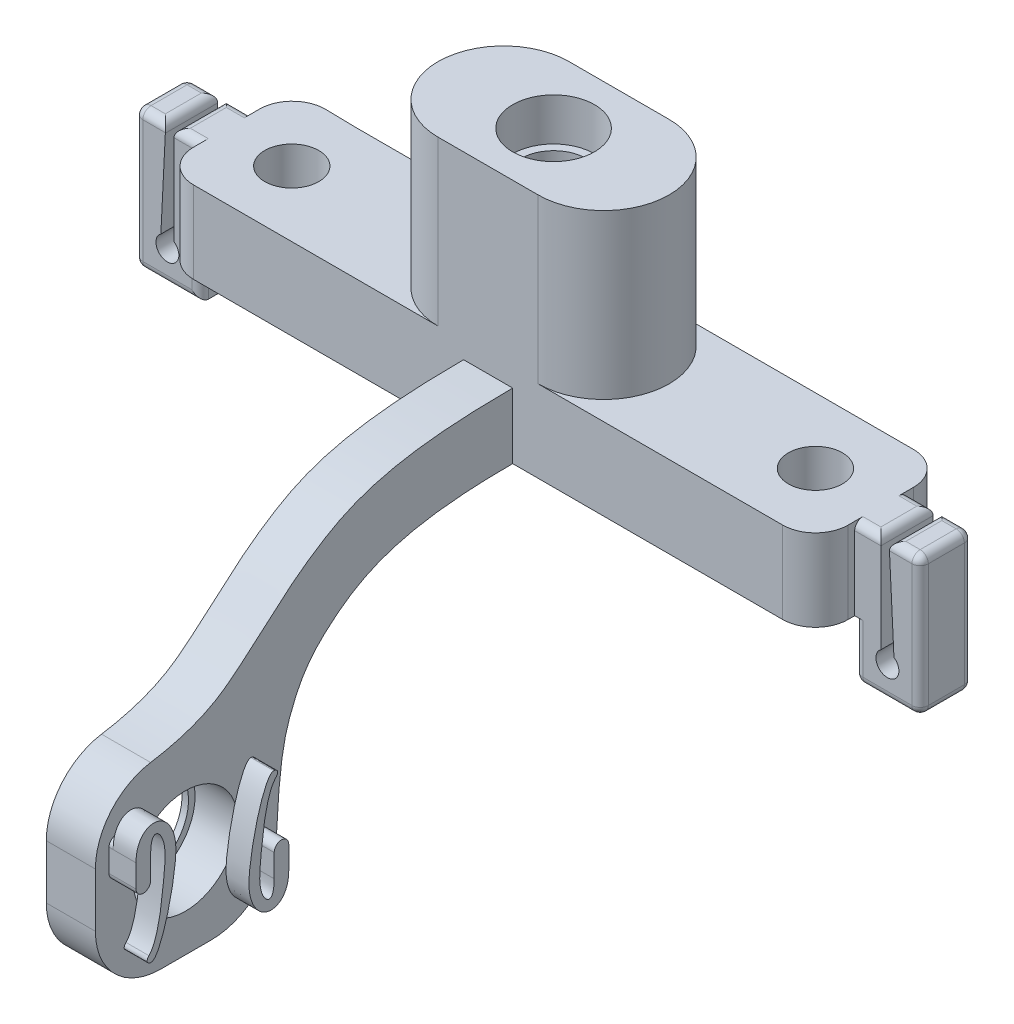
from build123d import *

# Parameters (mm, degrees)
SKETCH1_R                      = 1.65
BOSS_EXTRUDE1_DEPTH            = 5
SKETCH6_R                      = 2.5
CUT_EXTRUDE1_DEPTH             = 2.6
BOSS_EXTRUDE2_DEPTH            = 10
SKETCH8_R                      = 2.5
CUT_EXTRUDE2_DEPTH             = 2.6
SKETCH9_R                      = 2
CUT_EXTRUDE3_DEPTH             = 1.0000001
CUT_EXTRUDE3_DEPTH_BACK        = 16.0000001
BOSS_EXTRUDE3_DEPTH            = 1.6
BOSS_EXTRUDE3_DEPTH_BACK       = 1.6
CUT_EXTRUDE4_REACH             = 6.069
CUT_EXTRUDE4_DIRECTION_2_REACH = 6
FILLET1_R                      = 0.5
FILLET2_R                      = 2
SKETCH14_R                     = 3.19
BOSS_EXTRUDE5_DEPTH            = 1.5
BOSS_EXTRUDE5_DEPTH_BACK       = 1.5
FILLET3_R                      = 4
BOSS_EXTRUDE6_START            = 0.25
BOSS_EXTRUDE6_DEPTH            = 1.4
BOSS_EXTRUDE6_2_DEPTH          = 1.4
BOSS_EXTRUDE7_DEPTH            = 0.25
SKETCH17_R                     = 3.19
SKETCH17_R_2                   = 2.79
BOSS_EXTRUDE8_DEPTH            = 0.4


with BuildPart() as part:
    # Sketch1 → Boss-Extrude1 (new body)
    with BuildSketch(Plane(origin=(0, 0, 0), x_dir=(1, 0, 0), z_dir=(0, 1, 0))):
        with BuildLine():
            Line((16, -4), (20, -4))
            Line((20, -4), (20, 4))
            Line((20, 4), (16, 4))
            add(Edge.make_bspline(
                [(16, 4), (9.039795661, 4), (0.632100921, 4), (-10.303997503, 4), (-16, 4)],
                knots=[0, 0, 0, 0, 0.5, 1, 1, 1, 1], degree=3))
            Line((-16, 4), (-20, 4.068954941))
            Line((-20, 4.068954941), (-20, -4))
            Line((-20, -4), (-16, -4))
            add(Edge.make_bspline(
                [(16, -4), (10.303997503, -4), (-0.632100921, -4), (-9.039795661, -4), (-16, -4)],
                knots=[0, 0, 0, 0, 0.5, 1, 1, 1, 1], degree=3))
        make_face()
        with Locations((-16, 0)):
            Circle(SKETCH1_R, mode=Mode.SUBTRACT)
        with Locations((16, 0)):
            Circle(SKETCH1_R, mode=Mode.SUBTRACT)
    extrude(amount=BOSS_EXTRUDE1_DEPTH)

    # Sketch6 → Cut-Extrude1 (cut)
    with BuildSketch(Plane.XZ):
        Circle(SKETCH6_R)
    extrude(amount=-CUT_EXTRUDE1_DEPTH, mode=Mode.SUBTRACT)

    # Sketch7 → Boss-Extrude2 (add)
    with BuildSketch(Plane(origin=(0, 5, 0), x_dir=(1, 0, 0), z_dir=(0, 1, 0))):
        with BuildLine():
            Line((3.058707684, -4), (-3.058707684, -4))
            ThreePointArc((-3.058707684, -4), (-7.058707684, 0), (-3.058707684, 4))
            Line((-3.058707684, 4), (3.058707684, 4))
            ThreePointArc((3.058707684, 4), (7.058707684, 0), (3.058707684, -4))
        make_face()
    extrude(amount=BOSS_EXTRUDE2_DEPTH)

    # Sketch8 → Cut-Extrude2 (cut)
    with BuildSketch(Plane(origin=(0, 15, 0), x_dir=(1, 0, 0), z_dir=(0, 1, 0))):
        Circle(SKETCH8_R)
    extrude(amount=-CUT_EXTRUDE2_DEPTH, mode=Mode.SUBTRACT)

    # Sketch9 → Cut-Extrude3 (cut, two sides)
    with BuildSketch(Plane(origin=(0, 15, 0), x_dir=(1, 0, 0), z_dir=(0, 1, 0))) as cut_extrude3_sk:
        Circle(SKETCH9_R)
    extrude(amount=CUT_EXTRUDE3_DEPTH, mode=Mode.SUBTRACT)
    extrude(cut_extrude3_sk.sketch, amount=-CUT_EXTRUDE3_DEPTH_BACK, mode=Mode.SUBTRACT)

    # Sketch10 → Boss-Extrude3 (add, two sides)
    with BuildSketch(Plane.XY) as boss_extrude3_sk:
        Polygon((20, 5), (24, 5), (24, -3.5), (20, -3.5), (20, 0), align=None)
        Polygon((-20, -3.5), (-20, 0), (-20, 5), (-24, 5), (-24, -3.5), align=None)
    extrude(amount=BOSS_EXTRUDE3_DEPTH)
    extrude(boss_extrude3_sk.sketch, amount=-BOSS_EXTRUDE3_DEPTH_BACK)

    # Cut-Extrude4: up to this face of the body (flat: up to its plane)
    cut_extrude4_end = Plane(part.part.faces().sort_by_distance((-22, 0.75, -1.6))[0])
    # Sketch11 → Cut-Extrude4 (cut, up to the picked face)
    with BuildSketch(Plane.XY, mode=Mode.PRIVATE) as cut_extrude4_sk1:
        with BuildLine():
            Line((21.6, 5), (21.6, -1))
            ThreePointArc((21.6, -1), (22, -2.274456265), (22.4, -1))
            Line((22.4, -1), (22.1, 5))
            Line((22.1, 5), (21.6, 5))
        make_face()
    cut_extrude4_tool1 = split(extrude(cut_extrude4_sk1.sketch, amount=-CUT_EXTRUDE4_REACH, mode=Mode.PRIVATE), bisect_by=cut_extrude4_end, keep=Keep.BOTH, mode=Mode.PRIVATE)
    add(cut_extrude4_tool1.solids().sort_by_distance((21.949731, 0.845469, 0))[0], mode=Mode.SUBTRACT)
    # Sketch11 → Cut-Extrude4 (cut, up to the picked face)
    with BuildSketch(Plane.XY, mode=Mode.PRIVATE) as cut_extrude4_sk2:
        with BuildLine():
            Line((-22.1, 5), (-22.4, -1))
            ThreePointArc((-22.4, -1), (-22, -2.274456265), (-21.6, -1))
            Line((-21.6, -1), (-21.6, 5))
            Line((-21.6, 5), (-22.1, 5))
        make_face()
    cut_extrude4_tool2 = split(extrude(cut_extrude4_sk2.sketch, amount=-CUT_EXTRUDE4_REACH, mode=Mode.PRIVATE), bisect_by=cut_extrude4_end, keep=Keep.BOTH, mode=Mode.PRIVATE)
    add(cut_extrude4_tool2.solids().sort_by_distance((-21.949731, 0.845469, 0))[0], mode=Mode.SUBTRACT)

    # Cut-Extrude4 direction 2: up to this face of the body (flat: up to its plane)
    cut_extrude4_direction_2_end = Plane(part.part.faces().sort_by_distance((-22, 0.75, 1.6))[0])
    # Sketch11 → Cut-Extrude4 direction 2 (cut, up to the picked face)
    with BuildSketch(Plane.XY, mode=Mode.PRIVATE) as cut_extrude4_direction_2_sk1:
        with BuildLine():
            Line((21.6, 5), (21.6, -1))
            ThreePointArc((21.6, -1), (22, -2.274456265), (22.4, -1))
            Line((22.4, -1), (22.1, 5))
            Line((22.1, 5), (21.6, 5))
        make_face()
    cut_extrude4_direction_2_tool1 = split(extrude(cut_extrude4_direction_2_sk1.sketch, amount=CUT_EXTRUDE4_DIRECTION_2_REACH, mode=Mode.PRIVATE), bisect_by=cut_extrude4_direction_2_end, keep=Keep.BOTH, mode=Mode.PRIVATE)
    add(cut_extrude4_direction_2_tool1.solids().sort_by_distance((21.949731, 0.845469, 0))[0], mode=Mode.SUBTRACT)
    # Sketch11 → Cut-Extrude4 direction 2 (cut, up to the picked face)
    with BuildSketch(Plane.XY, mode=Mode.PRIVATE) as cut_extrude4_direction_2_sk2:
        with BuildLine():
            Line((-22.1, 5), (-22.4, -1))
            ThreePointArc((-22.4, -1), (-22, -2.274456265), (-21.6, -1))
            Line((-21.6, -1), (-21.6, 5))
            Line((-21.6, 5), (-22.1, 5))
        make_face()
    cut_extrude4_direction_2_tool2 = split(extrude(cut_extrude4_direction_2_sk2.sketch, amount=CUT_EXTRUDE4_DIRECTION_2_REACH, mode=Mode.PRIVATE), bisect_by=cut_extrude4_direction_2_end, keep=Keep.BOTH, mode=Mode.PRIVATE)
    add(cut_extrude4_direction_2_tool2.solids().sort_by_distance((-21.949731, 0.845469, 0))[0], mode=Mode.SUBTRACT)

    # Fillet1
    fillet1_edges = [part.edges().sort_by_distance(p)[0] for p in [
        (24, -3.5, 0),
        (-21.6, 5, 0),
        (-22.1, 5, 0),
        (22.1, 5, 0),
        (21.6, 5, 0),
        (20.8, 5, 1.6),
        (20.8, 5, -1.6),
        (24, 0.75, -1.6),
        (22, -3.5, -1.6),
        (-20.8, 5, -1.6),
        (-23.05, 5, -1.6),
        (-20, -1.75, -1.6),
        (-22, -3.5, -1.6),
        (-20, -1.75, 1.6),
        (20, -3.5, 0),
        (20, -1.75, -1.6),
        (23.05, 5, -1.6),
        (24, 5, 0),
        (23.05, 5, 1.6),
        (24, 0.75, 1.6),
        (22, -3.5, 1.6),
        (20, -1.75, 1.6),
        (-24, 0.75, -1.6),
        (-24, -3.5, 0),
        (-22, -3.5, 1.6),
        (-24, 0.75, 1.6),
        (-24, 5, 0),
        (-20.8, 5, 1.6),
        (-23.05, 5, 1.6),
    ]]
    fillet(fillet1_edges, radius=FILLET1_R)

    # Fillet2
    fillet2_edges = [part.edges().sort_by_distance(p)[0] for p in [
        (20, 2.5, -4),
        (20, 2.5, 4),
        (-20, 2.5, 4),
        (-20, 2.5, -4.068954941),
    ]]
    fillet(fillet2_edges, radius=FILLET2_R)

    # Sketch14 → Boss-Extrude5 (add, two sides)
    with BuildSketch(Plane(origin=(0, 0, 0), x_dir=(0, 0, -1), z_dir=(1, 0, 0))) as boss_extrude5_sk:
        with BuildLine():
            Line((-4, 0), (-4, 4))
            add(Edge.make_bspline(
                [(-29.5, -5), (-26.410383503, -5), (-22.948570509, -4.250228298), (-18.019340073, -0.168857427), (-18.065149482, 0.033738624), (-14.066504267, 2.807314175), (-10.811499642, 4), (-4, 4)],
                knots=[0, 0, 0, 0, 0.144419609, 0.201417983, 0.529031986, 0.612985363, 1, 1, 1, 1], degree=3))
            Line((-29.5, -5), (-29.5, -16))
            Line((-29.5, -16), (-18.5, -16))
            add(Edge.make_bspline(
                [(-18.5, -16), (-18.5, -13.924191296), (-18.412637706, -9.003083977), (-17.185578457, -5.224772611), (-16.289011656, -3.890884668), (-12.929327604, -1.053651793), (-9.805217888, 0), (-4, 0)],
                knots=[0, 0, 0, 0, 0.247521115, 0.303911059, 0.535011843, 0.607509497, 1, 1, 1, 1], degree=3))
        make_face()
        with Locations((-24, -10.5)):
            Circle(SKETCH14_R, mode=Mode.SUBTRACT)
    extrude(amount=BOSS_EXTRUDE5_DEPTH)
    extrude(boss_extrude5_sk.sketch, amount=-BOSS_EXTRUDE5_DEPTH_BACK)

    # Fillet3
    fillet3_edges = [part.edges().sort_by_distance(p)[0] for p in [
        (-0.75, -16, 18.5),
        (0, -16, 29.5),
        (0.75, -5, 29.5),
    ]]
    fillet(fillet3_edges, radius=FILLET3_R)



with BuildPart() as body_2:
    # Sketch15 → Boss-Extrude6 (new body)
    with BuildSketch(Plane(origin=(1.5, 0, 0), x_dir=(0, 0, -1), z_dir=(1, 0, 0)).offset(BOSS_EXTRUDE6_START)):
        with BuildLine():
            Line((-28.666210879, -7.967729847), (-28.666210879, -9.356744491))
            ThreePointArc((-28.666210879, -9.356744491), (-28.220354327, -9.802601044), (-27.774497774, -9.356744491))
            Line((-27.774497774, -9.356744491), (-27.774497774, -7.967729847))
            add(Edge.make_bspline(
                [(-27.774497774, -7.967729847), (-27.774497774, -7.486639997), (-27.587216201, -6.632399005), (-26.78753653, -7.529872477), (-27.070399998, -10.875883099), (-27.338302047, -12.696265898), (-27.878636725, -13.275195911)],
                knots=[0, 0, 0, 0, 0.169550868, 0.45941283, 0.542457744, 1, 1, 1, 1], degree=3))
            add(Edge.make_bspline(
                [(-27.878636725, -13.275195911), (-27.980476701, -13.384310171), (-28.034408559, -13.542329446), (-27.824126851, -13.715787117), (-27.792031832, -13.684938013), (-27.764124123, -13.690324606)],
                knots=[0, 0, 0, 0, 0.416220301, 0.516220301, 1, 1, 1, 1], degree=3))
            add(Edge.make_bspline(
                [(-28.666210879, -7.967729847), (-28.666210879, -6.845932215), (-27.363875572, -5.828940912), (-26.144909701, -7.368237019), (-26.358417864, -10.696475866), (-27.257328091, -13.788143607), (-27.764124123, -13.690324606)],
                knots=[0, 0, 0, 0, 0.217283581, 0.494281677, 0.572553319, 1, 1, 1, 1], degree=3))
        make_face()
    extrude(amount=BOSS_EXTRUDE6_DEPTH)


with BuildPart() as body_3:
    # Sketch15 → Boss-Extrude6 2 (new body)
    with BuildSketch(Plane(origin=(1.5, 0, 0), x_dir=(0, 0, -1), z_dir=(1, 0, 0)).offset(BOSS_EXTRUDE6_START)):
        with BuildLine():
            Line((-19.333789121, -13.032270153), (-19.333789121, -11.643255509))
            ThreePointArc((-19.333789121, -11.643255509), (-19.779645673, -11.197398956), (-20.225502226, -11.643255509))
            Line((-20.225502226, -11.643255509), (-20.225502226, -13.032270153))
            add(Edge.make_bspline(
                [(-20.225502226, -13.032270153), (-20.225502226, -13.513360003), (-20.412783799, -14.367600995), (-21.21246347, -13.470127523), (-20.929600002, -10.124116901), (-20.661697953, -8.303734102), (-20.121363275, -7.724804089)],
                knots=[0, 0, 0, 0, 0.169550868, 0.45941283, 0.542457744, 1, 1, 1, 1], degree=3))
            add(Edge.make_bspline(
                [(-20.121363275, -7.724804089), (-20.019523299, -7.615689829), (-19.965591441, -7.457670554), (-20.175873149, -7.284212883), (-20.207968168, -7.315061987), (-20.235875877, -7.309675394)],
                knots=[0, 0, 0, 0, 0.416220301, 0.516220301, 1, 1, 1, 1], degree=3))
            add(Edge.make_bspline(
                [(-19.333789121, -13.032270153), (-19.333789121, -14.154067785), (-20.636124428, -15.171059088), (-21.855090299, -13.631762981), (-21.641582136, -10.303524134), (-20.742671909, -7.211856393), (-20.235875877, -7.309675394)],
                knots=[0, 0, 0, 0, 0.217283581, 0.494281677, 0.572553319, 1, 1, 1, 1], degree=3))
        make_face()
    extrude(amount=BOSS_EXTRUDE6_2_DEPTH)


with BuildPart() as part_1:
    add(part.part)

    add(body_2.part)  # Boss-Extrude7 merges body 2

    add(body_3.part)  # Boss-Extrude7 merges body 3
    # Sketch16 → Boss-Extrude7 (add)
    with BuildSketch(Plane.ZY.offset(-1.75)):
        with BuildLine():
            Line((19.333789121, -13.032270153), (19.333789121, -11.643255509))
            ThreePointArc((19.333789121, -11.643255509), (19.779645673, -11.197398956), (20.225502226, -11.643255509))
            Line((20.225502226, -11.643255509), (20.225502226, -13.032270153))
            ThreePointArc((20.225502226, -13.032270153), (19.779645673, -13.478126705), (19.333789121, -13.032270153))
        make_face()
        with BuildLine():
            Line((27.774497774, -9.356744491), (27.774497774, -7.967729847))
            ThreePointArc((27.774497774, -7.967729847), (28.220354327, -7.521873295), (28.666210879, -7.967729847))
            Line((28.666210879, -7.967729847), (28.666210879, -9.356744491))
            ThreePointArc((28.666210879, -9.356744491), (28.220354327, -9.802601044), (27.774497774, -9.356744491))
        make_face()
    extrude(amount=BOSS_EXTRUDE7_DEPTH)

    # Sketch17 → Boss-Extrude8 (add)
    with BuildSketch(Plane.ZY.offset(1.5)):
        with Locations((24, -10.5)):
            Circle(SKETCH17_R)
        with Locations((24, -10.5)):
            Circle(SKETCH17_R_2, mode=Mode.SUBTRACT)
    extrude(amount=-BOSS_EXTRUDE8_DEPTH)


solid = part_1.part
